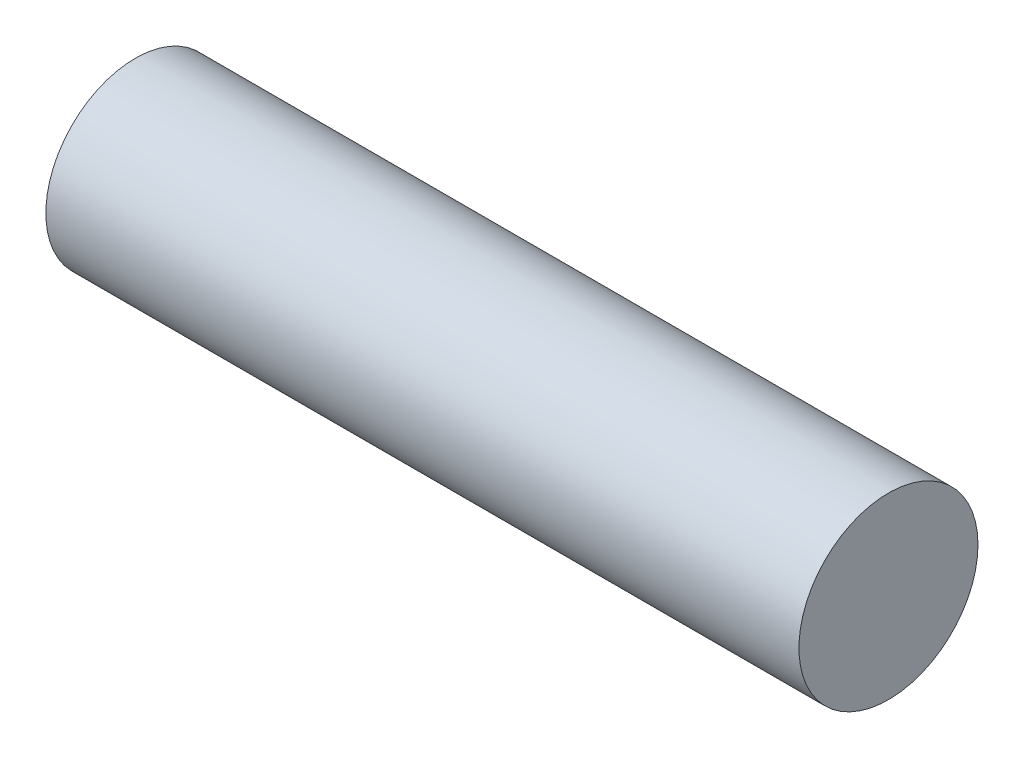
from build123d import *

# Parameters (mm, degrees)
SKETCH1_R           = 10.75
SKETCH1_R_2         = 10
BOSS_EXTRUDE1_DEPTH = 89.43
SKETCH2_R           = 10.75
BOSS_EXTRUDE2_DEPTH = 1


with BuildPart() as part:
    # Sketch1 → Boss-Extrude1 (new body)
    with BuildSketch(Plane(origin=(0, 0, 0), x_dir=(0, 0, -1), z_dir=(1, 0, 0))):
        Circle(SKETCH1_R)
        Circle(SKETCH1_R_2, mode=Mode.SUBTRACT)
    extrude(amount=BOSS_EXTRUDE1_DEPTH)

    # Sketch2 → Boss-Extrude2 (add)
    with BuildSketch(Plane(origin=(89.43, 0, 0), x_dir=(0, 0, -1), z_dir=(1, 0, 0))):
        Circle(SKETCH2_R)
    extrude(amount=BOSS_EXTRUDE2_DEPTH)


solid = part.part
